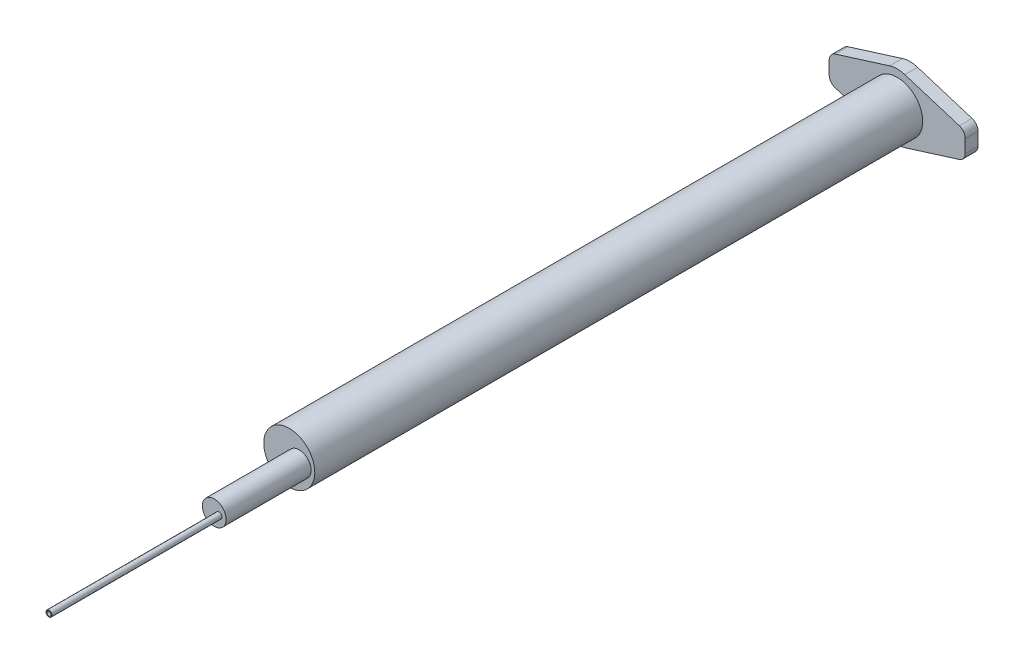
from build123d import *

# Parameters (mm, degrees)
SKETCH_1_R      = 3
SKETCH_1_R_2    = 2.5
EXTRUDE_1_DEPTH = 71.5
SKETCH_2_R      = 3
SKETCH_2_R_2    = 1
EXTRUDE_2_DEPTH = 1
SKETCH_3_R      = 2.5
EXTRUDE_3_DEPTH = 1.5
SKETCH_4_R      = 1.4
SKETCH_4_R_2    = 1
EXTRUDE_4_DEPTH = 9
SKETCH_5_R      = 1.4
SKETCH_5_R_2    = 0.25
EXTRUDE_5_DEPTH = 1
SKETCH_6_R      = 0.35
SKETCH_6_R_2    = 0.25
EXTRUDE_6_DEPTH = 20


with BuildPart() as part:
    # 草图1 → 凸台-拉伸1 (new body)
    with BuildSketch(Plane.XY):
        Circle(SKETCH_1_R)
        Circle(SKETCH_1_R_2, mode=Mode.SUBTRACT)
    extrude(amount=EXTRUDE_1_DEPTH)

    # 草图2 → 凸台-拉伸2 (add)
    with BuildSketch(Plane.XY.offset(71.5)):
        Circle(SKETCH_2_R)
        with Locations((1.174015937, 0)):
            Circle(SKETCH_2_R_2, mode=Mode.SUBTRACT)
    extrude(amount=-EXTRUDE_2_DEPTH)

    # 草图3 → 凸台-拉伸3 (add)
    with BuildSketch(Plane(origin=(0, 0, 0), x_dir=(-1, 0, 0), z_dir=(0, 0, -1))):
        with BuildLine():
            Line((7.298274993, -1.719289065), (0.894824979, -3.720367194))
            ThreePointArc((0.894824979, -3.720367194), (0, -3.85692726), (-0.894824979, -3.720367194))
            Line((-0.894824979, -3.720367194), (-7.298274993, -1.719289065))
            ThreePointArc((-7.298274993, -1.719289065), (-7.805690695, -1.357145565), (-8, -0.764809087))
            Line((-8, -0.764809087), (-8, 0))
            Line((-8, 0), (-8, 0.764809087))
            ThreePointArc((-8, 0.764809087), (-7.805690695, 1.357145565), (-7.298274993, 1.719289065))
            Line((-7.298274993, 1.719289065), (-0.894824979, 3.720367194))
            ThreePointArc((-0.894824979, 3.720367194), (0, 3.85692726), (0.894824979, 3.720367194))
            Line((0.894824979, 3.720367194), (7.298274993, 1.719289065))
            ThreePointArc((7.298274993, 1.719289065), (7.805690695, 1.357145565), (8, 0.764809087))
            Line((8, 0.764809087), (8, 0))
            Line((8, 0), (8, -0.764809087))
            ThreePointArc((8, -0.764809087), (7.805690695, -1.357145565), (7.298274993, -1.719289065))
        make_face()
        Circle(SKETCH_3_R, mode=Mode.SUBTRACT)
    extrude(amount=EXTRUDE_3_DEPTH)

    # 草图4 → 凸台-拉伸4 (add)
    with BuildSketch(Plane.XY.offset(71.5)):
        with Locations((1.174015937, 0)):
            Circle(SKETCH_4_R)
        with Locations((1.174015937, 0)):
            Circle(SKETCH_4_R_2, mode=Mode.SUBTRACT)
    extrude(amount=EXTRUDE_4_DEPTH)

    # 草图5 → 凸台-拉伸5 (add)
    with BuildSketch(Plane.XY.offset(80.5)):
        with Locations((1.174015937, 0)):
            Circle(SKETCH_5_R)
        with Locations((1.74042038, 0)):
            Circle(SKETCH_5_R_2, mode=Mode.SUBTRACT)
    extrude(amount=EXTRUDE_5_DEPTH)

    # 草图6 → 凸台-拉伸6 (add)
    with BuildSketch(Plane.XY.offset(81.5)):
        with Locations((1.74042038, 0)):
            Circle(SKETCH_6_R)
        with Locations((1.74042038, 0)):
            Circle(SKETCH_6_R_2, mode=Mode.SUBTRACT)
    extrude(amount=EXTRUDE_6_DEPTH)


solid = part.part
